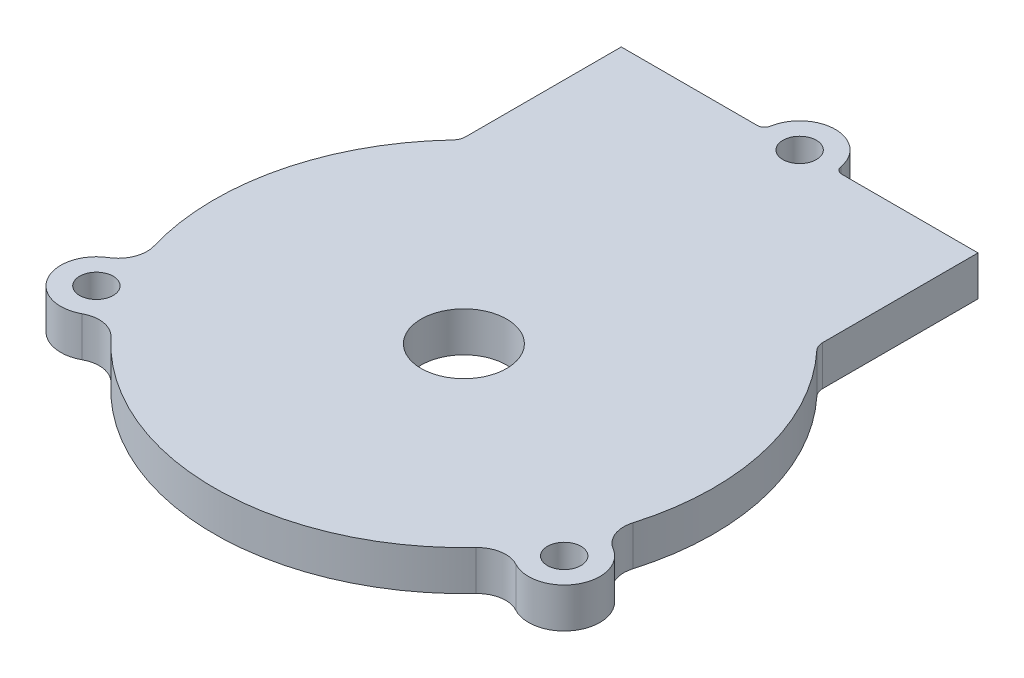
from build123d import *

# Parameters (mm, degrees)
SKETCH1_R                  = 35
SKETCH1_R_2                = 6
SKETCH1_R_3                = 5
SKETCH1_W                  = 50
SKETCH1_H                  = 25
BOSS_EXTRUDE2_DEPTH        = 5.588
F_4_7_4_7_DIAMETER_HOLE1_D = 4.7
FILLET1_R                  = 1
FILLET2_R                  = 1
FILLET6_R                  = 4
FILLET7_R                  = 4
FILLET8_R                  = 4
FILLET9_R                  = 2
FILLET10_R                 = 2


with BuildPart() as part:
    # Sketch1 → Boss-Extrude2 (new body)
    with BuildSketch(Plane(origin=(0, 0, 0), x_dir=(1, 0, 0), z_dir=(0, 1, 0))):
        with Locations((32.785, 18.724314586)):
            Circle(SKETCH1_R)
        with Locations((32.785, 18.724314586)):
            Circle(SKETCH1_R_2, mode=Mode.SUBTRACT)
        with Locations((65.57, 0)):
            Circle(SKETCH1_R_3)
        Circle(SKETCH1_R_3)
        with Locations((32.785, 65.782929207)):
            Circle(SKETCH1_R_3)
        with Locations((32.785, 53.282929207)):
            Rectangle(SKETCH1_W, SKETCH1_H)
    extrude(amount=BOSS_EXTRUDE2_DEPTH)

    # Ø4.7 (4.7) Diameter Hole1 (through all)
    with Locations(Plane(origin=(0, 5.588, 0), x_dir=(1, 0, 0), z_dir=(0, 1, 0))):
        with Locations((0, 0), (65.57, 0), (32.785, 65.782929207)):
            Hole(F_4_7_4_7_DIAMETER_HOLE1_D / 2)

    # Fillet1
    fillet1_edges = [part.edges().sort_by_distance(p)[0] for p in [
        (27.785, 2.794, -65.782929207),
    ]]
    fillet(fillet1_edges, radius=FILLET1_R)

    # Fillet2
    fillet2_edges = [part.edges().sort_by_distance(p)[0] for p in [
        (37.785, 2.794, -65.782929207),
    ]]
    fillet(fillet2_edges, radius=FILLET2_R)

    # Fillet6
    fillet6_edges = [part.edges().sort_by_distance(p)[0] for p in [
        (0.603671593, 2.794, -4.963424282),
    ]]
    fillet(fillet6_edges, radius=FILLET6_R)

    # Fillet7
    fillet7_edges = [part.edges().sort_by_distance(p)[0] for p in [
        (4.581742742, 2.794, 2.001907453),
    ]]
    fillet(fillet7_edges, radius=FILLET7_R)

    # Fillet8
    fillet8_edges = [part.edges().sort_by_distance(p)[0] for p in [
        (60.988257258, 2.794, 2.001907453),
        (64.966328407, 2.794, -4.963424282),
    ]]
    fillet(fillet8_edges, radius=FILLET8_R)

    # Fillet9
    fillet9_edges = [part.edges().sort_by_distance(p)[0] for p in [
        (57.785, 2.794, -43.219212014),
    ]]
    fillet(fillet9_edges, radius=FILLET9_R)

    # Fillet10
    fillet10_edges = [part.edges().sort_by_distance(p)[0] for p in [
        (7.785, 2.794, -43.219212014),
    ]]
    fillet(fillet10_edges, radius=FILLET10_R)


solid = part.part
